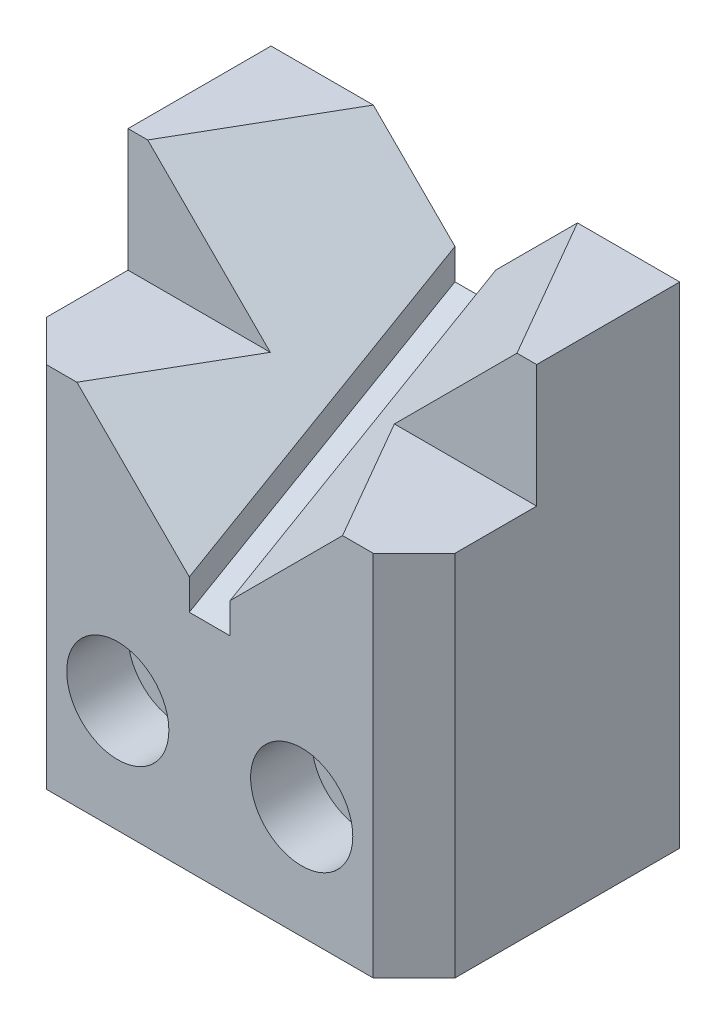
from build123d import *

# Parameters (mm, degrees)
BOSS_EXTRUDE1_DEPTH = 31.75
SKETCH2_R           = 7.9375
CUT_EXTRUDE1_DEPTH  = 9.525
SKETCH2_4_R         = 4.7625
CUT_EXTRUDE2_DEPTH  = 93.293705771
CUT_EXTRUDE3_DEPTH  = 107.726292282
CHAMFER1_SIZE       = 6.35


with BuildPart() as part:
    # Sketch1 → Boss-Extrude1 (new, symmetric)
    with BuildSketch(Plane(origin=(0, 0, 0), x_dir=(0, 0, -1), z_dir=(1, 0, 0))):
        Polygon((20.6375, 76.2), (20.6375, 0), (-20.6375, 0), (-20.6375, 57.15), (-1.5875, 57.15), (-1.5875, 76.2), align=None)
    extrude(amount=BOSS_EXTRUDE1_DEPTH, both=True)

    # Sketch2 → Cut-Extrude1 (cut)
    with BuildSketch(Plane.XY.offset(20.6375)):
        with Locations((14.2875, 17.4625)):
            Circle(SKETCH2_R)
        with Locations((-14.2875, 17.4625)):
            Circle(SKETCH2_R)
    extrude(amount=-CUT_EXTRUDE1_DEPTH, mode=Mode.SUBTRACT)

    # Sketch2_4 → Cut-Extrude2 (cut, through all)
    with BuildSketch(Plane.XY.offset(20.6375)):
        with Locations((14.2875, 17.4625)):
            Circle(SKETCH2_4_R)
        with Locations((-14.2875, 17.4625)):
            Circle(SKETCH2_4_R)
    extrude(amount=-CUT_EXTRUDE2_DEPTH, mode=Mode.SUBTRACT)

    # Sketch3 → Cut-Extrude3 (cut, through all, along a direction that is not the sketch's normal)
    with BuildSketch(Plane.XY.offset(20.6375)):
        Polygon((-39.6875, 76.2), (-3.175, 39.6875), (-3.175, 34.925), (3.175, 34.925), (3.175, 39.6875), (39.6875, 76.2), align=None)
    extrude(amount=-CUT_EXTRUDE3_DEPTH, dir=(0, -0.49999999999999806, 0.8660254037844398), mode=Mode.SUBTRACT)

    # Chamfer1
    chamfer1_edges = [part.edges().sort_by_distance(p)[0] for p in [
        (-31.75, 28.575, 20.6375),
        (31.75, 28.575, 20.6375),
    ]]
    chamfer(chamfer1_edges, length=CHAMFER1_SIZE)


solid = part.part
